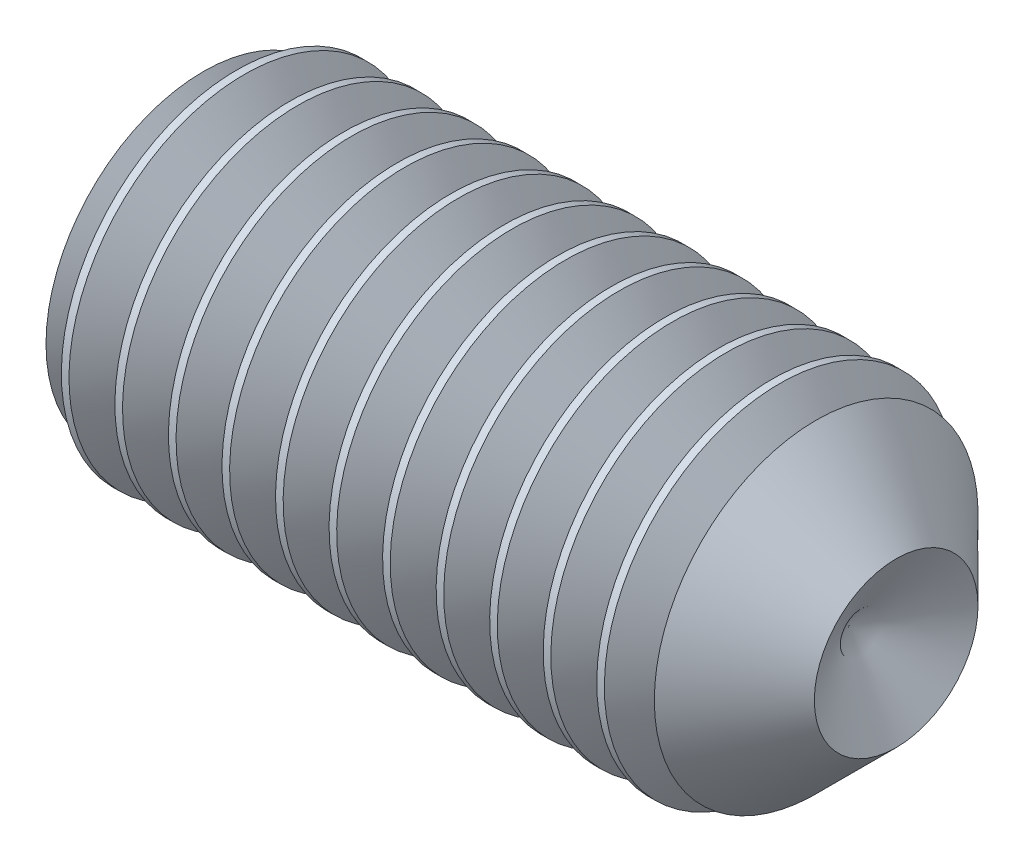
from build123d import *

# Parameters (mm, degrees)
HEX_2_DEPTH     = 2
THDSCHPAT_COUNT = 12
THDSCHPAT_PITCH = 0.458004843


with BuildPart() as part:
    # BodySke → BaseBody (revolve)
    with BuildSketch(Plane.XY):
        Polygon((0, 0), (0, 1.2195), (0.161946751, 1.5), (5.2, 1.5), (6, 0.7), (5.595854812, 0), align=None)
    revolve(axis=Axis((-12.7, 0, 0), (1, 0, 0)))

    # Sketch2 → Hex 2 (cut)
    with BuildSketch(Plane.ZY):
        Polygon((0.433012702, 0.75), (-0.433012702, 0.75), (-0.866025404, 0), (-0.433012702, -0.75), (0.433012702, -0.75), (0.866025404, 0), align=None)
    extrude(amount=-HEX_2_DEPTH, mode=Mode.SUBTRACT)

    # ThdSchSke → ThreadSchematic (revolve, cut)
    with BuildSketch(Plane.XY):
        Polygon((0.161946751, -1.2195), (-0.034461464, -1.5), (-0.034461464, -1.875), (0.358354965, -1.875), (0.358354965, -1.5), align=None)
    threadschematic = revolve(axis=Axis((-3.175, 0, 0), (1, 0, 0)), mode=Mode.SUBTRACT)

    # ThdSchPat: ThreadSchematic ×12
    with Locations(*[(i * THDSCHPAT_PITCH, 0, 0) for i in range(1, THDSCHPAT_COUNT)]):
        add(threadschematic, mode=Mode.SUBTRACT)


solid = part.part
